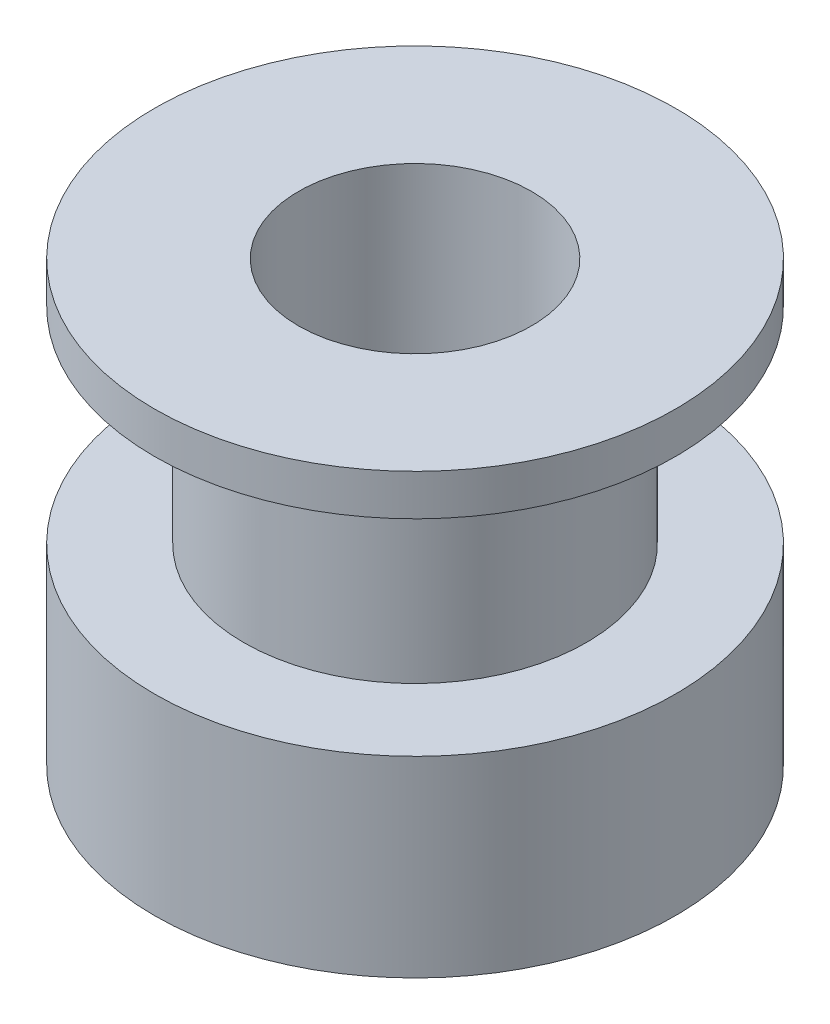
from build123d import *

# Parameters (mm, degrees)
SKETCH1_R           = 9.5
BOSS_EXTRUDE1_DEPTH = 7
SKETCH2_R           = 6.25
BOSS_EXTRUDE2_DEPTH = 7.5
SKETCH3_R           = 9.5
BOSS_EXTRUDE3_DEPTH = 1.5
SKETCH4_R           = 4.25
CUT_EXTRUDE1_DEPTH  = 17


with BuildPart() as part:
    # Sketch1 → Boss-Extrude1 (new body)
    with BuildSketch(Plane(origin=(0, 0, 0), x_dir=(1, 0, 0), z_dir=(0, 1, 0))):
        Circle(SKETCH1_R)
    extrude(amount=BOSS_EXTRUDE1_DEPTH)

    # Sketch2 → Boss-Extrude2 (add)
    with BuildSketch(Plane(origin=(0, 7, 0), x_dir=(1, 0, 0), z_dir=(0, 1, 0))):
        Circle(SKETCH2_R)
    extrude(amount=BOSS_EXTRUDE2_DEPTH)

    # Sketch3 → Boss-Extrude3 (add)
    with BuildSketch(Plane(origin=(0, 14.5, 0), x_dir=(1, 0, 0), z_dir=(0, 1, 0))):
        Circle(SKETCH3_R)
    extrude(amount=BOSS_EXTRUDE3_DEPTH)

    # Sketch4 → Cut-Extrude1 (cut, through all)
    with BuildSketch(Plane(origin=(0, 16, 0), x_dir=(1, 0, 0), z_dir=(0, 1, 0))):
        Circle(SKETCH4_R)
    extrude(amount=-CUT_EXTRUDE1_DEPTH, mode=Mode.SUBTRACT)


solid = part.part
